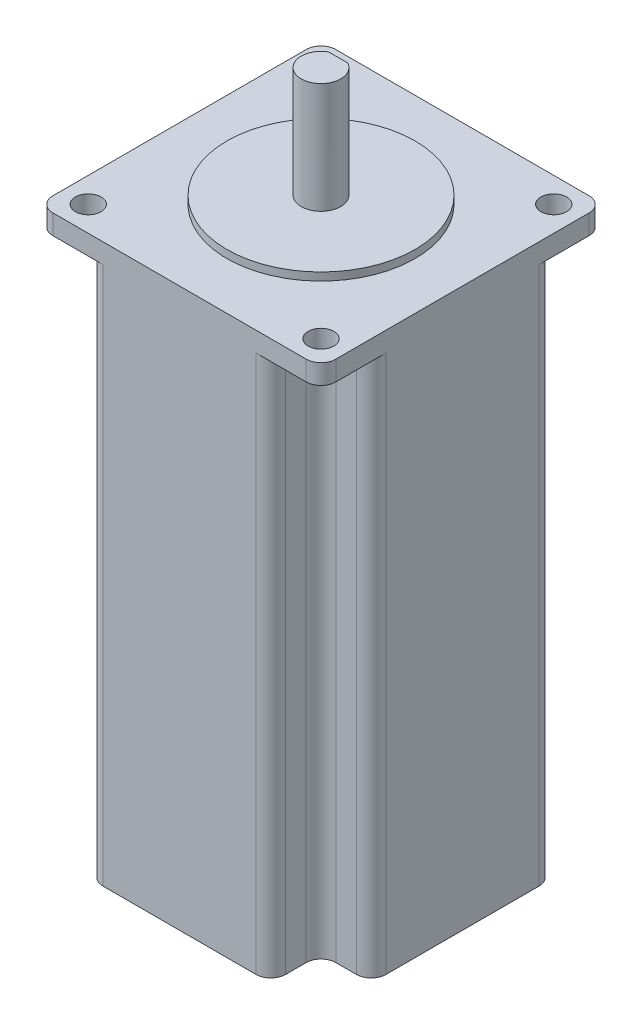
from build123d import *

# Parameters (mm, degrees)
SKETCH1_R           = 2.6
BOSS_EXTRUDE1_DEPTH = 4
SKETCH2_R           = 19.05
BOSS_EXTRUDE2_DEPTH = 1.6
SKETCH3_R           = 4
BOSS_EXTRUDE3_DEPTH = 22.4
CUT_EXTRUDE1_DEPTH  = 20
BOSS_EXTRUDE4_DEPTH = 109


with BuildPart() as part:
    # Sketch1 → Boss-Extrude1 (new body)
    with BuildSketch(Plane(origin=(0, 0, 0), x_dir=(1, 0, 0), z_dir=(0, 1, 0))):
        with BuildLine():
            Line((25.65, -28.65), (-25.65, -28.65))
            ThreePointArc((-25.65, -28.65), (-27.771320344, -27.771320344), (-28.65, -25.65))
            Line((-28.65, -25.65), (-28.65, 25.65))
            ThreePointArc((-28.65, 25.65), (-27.771320344, 27.771320344), (-25.65, 28.65))
            Line((-25.65, 28.65), (25.65, 28.65))
            ThreePointArc((25.65, 28.65), (27.771320344, 27.771320344), (28.65, 25.65))
            Line((28.65, 25.65), (28.65, -25.65))
            ThreePointArc((28.65, -25.65), (27.771320344, -27.771320344), (25.65, -28.65))
        make_face()
        with Locations((-23.57, 23.57)):
            Circle(SKETCH1_R, mode=Mode.SUBTRACT)
        with Locations((23.57, 23.57)):
            Circle(SKETCH1_R, mode=Mode.SUBTRACT)
        with Locations((23.57, -23.57)):
            Circle(SKETCH1_R, mode=Mode.SUBTRACT)
        with Locations((-23.57, -23.57)):
            Circle(SKETCH1_R, mode=Mode.SUBTRACT)
    extrude(amount=-BOSS_EXTRUDE1_DEPTH)

    # Sketch2 → Boss-Extrude2 (add)
    with BuildSketch(Plane(origin=(0, 0, 0), x_dir=(1, 0, 0), z_dir=(0, 1, 0))):
        Circle(SKETCH2_R)
    extrude(amount=BOSS_EXTRUDE2_DEPTH)

    # Sketch3 → Boss-Extrude3 (add)
    with BuildSketch(Plane(origin=(0, 1.6, 0), x_dir=(1, 0, 0), z_dir=(0, 1, 0))):
        Circle(SKETCH3_R)
    extrude(amount=BOSS_EXTRUDE3_DEPTH)

    # Sketch4 → Cut-Extrude1 (cut)
    with BuildSketch(Plane(origin=(0, 24, 0), x_dir=(1, 0, 0), z_dir=(0, 1, 0))):
        with BuildLine():
            Line((-1.936491673, 3.5), (1.936491673, 3.5))
            ThreePointArc((1.936491673, 3.5), (0, 4), (-1.936491673, 3.5))
        make_face()
    extrude(amount=-CUT_EXTRUDE1_DEPTH, mode=Mode.SUBTRACT)

    # Sketch5 → Boss-Extrude4 (add)
    with BuildSketch(Plane.XZ.offset(4)):
        with BuildLine():
            Line((-18.49, 25.65), (-18.49, 21.49))
            ThreePointArc((-18.49, 21.49), (-19.368679656, 19.368679656), (-21.49, 18.49))
            Line((-21.49, 18.49), (-25.65, 18.49))
            ThreePointArc((-25.65, 18.49), (-27.771320344, 17.611320344), (-28.65, 15.49))
            Line((-28.65, 15.49), (-28.65, -15.49))
            ThreePointArc((-28.65, -15.49), (-27.771320344, -17.611320344), (-25.65, -18.49))
            Line((-25.65, -18.49), (-21.49, -18.49))
            ThreePointArc((-21.49, -18.49), (-19.368679656, -19.368679656), (-18.49, -21.49))
            Line((-18.49, -21.49), (-18.49, -25.65))
            ThreePointArc((-18.49, -25.65), (-17.611320344, -27.771320344), (-15.49, -28.65))
            Line((-15.49, -28.65), (15.49, -28.65))
            ThreePointArc((15.49, -28.65), (17.611320344, -27.771320344), (18.49, -25.65))
            Line((18.49, -25.65), (18.49, -21.49))
            ThreePointArc((18.49, -21.49), (19.368679656, -19.368679656), (21.49, -18.49))
            Line((21.49, -18.49), (25.65, -18.49))
            ThreePointArc((25.65, -18.49), (27.771320344, -17.611320344), (28.65, -15.49))
            Line((28.65, -15.49), (28.65, 15.49))
            ThreePointArc((28.65, 15.49), (27.771320344, 17.611320344), (25.65, 18.49))
            Line((25.65, 18.49), (21.49, 18.49))
            ThreePointArc((21.49, 18.49), (19.368679656, 19.368679656), (18.49, 21.49))
            Line((18.49, 21.49), (18.49, 25.65))
            ThreePointArc((18.49, 25.65), (17.611320344, 27.771320344), (15.49, 28.65))
            Line((15.49, 28.65), (-15.49, 28.65))
            ThreePointArc((-15.49, 28.65), (-17.611320344, 27.771320344), (-18.49, 25.65))
        make_face()
    extrude(amount=BOSS_EXTRUDE4_DEPTH)


solid = part.part
